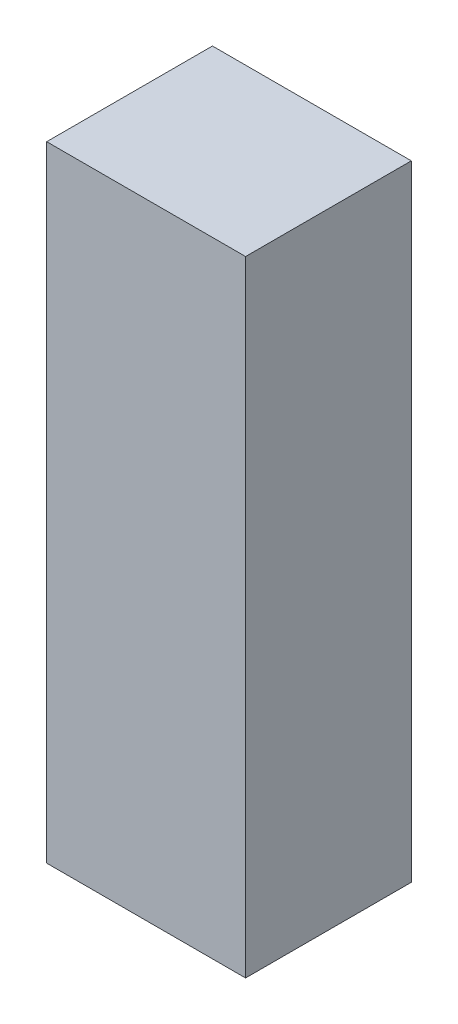
from build123d import *

# Parameters (mm, degrees)
SCHIZZO1_W                   = 12
SCHIZZO1_H                   = 37.699
ESTRUSIONE_ESTRUSIONE1_DEPTH = 10


with BuildPart() as part:
    # Schizzo1 → Estrusione-Estrusione1 (new body)
    with BuildSketch(Plane.XY):
        with Locations((6, 18.8495)):
            Rectangle(SCHIZZO1_W, SCHIZZO1_H)
    extrude(amount=ESTRUSIONE_ESTRUSIONE1_DEPTH)


solid = part.part
